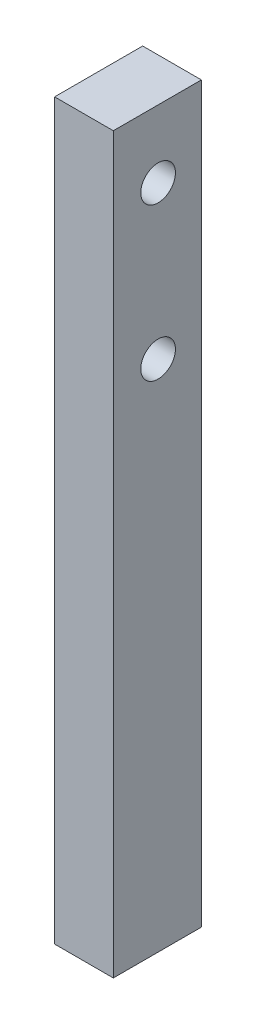
from build123d import *

# Parameters (mm, degrees)
SKETCH1_W           = 5.08
SKETCH1_H           = 63.5
BOSS_EXTRUDE1_DEPTH = 7.62
SKETCH2_R           = 1.5
CUT_EXTRUDE1_DEPTH  = 6.08


with BuildPart() as part:
    # Sketch1 → Boss-Extrude1 (new body)
    with BuildSketch(Plane.XY):
        with Locations((2.54, 31.75)):
            Rectangle(SKETCH1_W, SKETCH1_H)
    extrude(amount=BOSS_EXTRUDE1_DEPTH)

    # Sketch2 → Cut-Extrude1 (cut, through all)
    with BuildSketch(Plane.ZY):
        with Locations((3.744499847, 57.658)):
            Circle(SKETCH2_R)
        with Locations((3.744499847, 44.45)):
            Circle(SKETCH2_R)
    extrude(amount=-CUT_EXTRUDE1_DEPTH, mode=Mode.SUBTRACT)


solid = part.part
